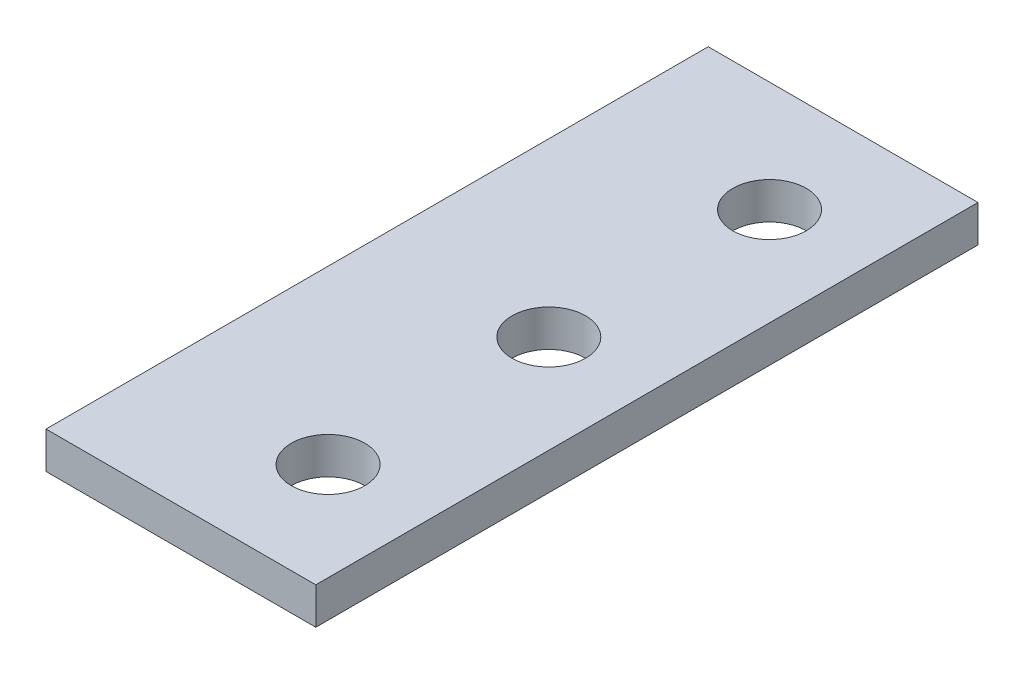
from build123d import *

# Parameters (mm, degrees)
SKETCH1_R           = 9
BOSS_EXTRUDE1_DEPTH = 9


with BuildPart() as part:
    # Sketch1 → Boss-Extrude1 (new body)
    with BuildSketch(Plane(origin=(0, 0, 0), x_dir=(1, 0, 0), z_dir=(0, 1, 0))):
        Polygon((-31.51785791, 97.556603774), (34.48214209, 97.556603774), (34.48214209, -40.443396226), (34.48214209, -64.443396226), (10.48214209, -64.443396226), (-31.51785791, -64.443396226), align=None)
        with Locations((10.48214209, -37.443396226)):
            Circle(SKETCH1_R, mode=Mode.SUBTRACT)
        with Locations((10.48214209, 16.556603774)):
            Circle(SKETCH1_R, mode=Mode.SUBTRACT)
        with Locations((10.48214209, 70.556603774)):
            Circle(SKETCH1_R, mode=Mode.SUBTRACT)
    extrude(amount=BOSS_EXTRUDE1_DEPTH)


solid = part.part
